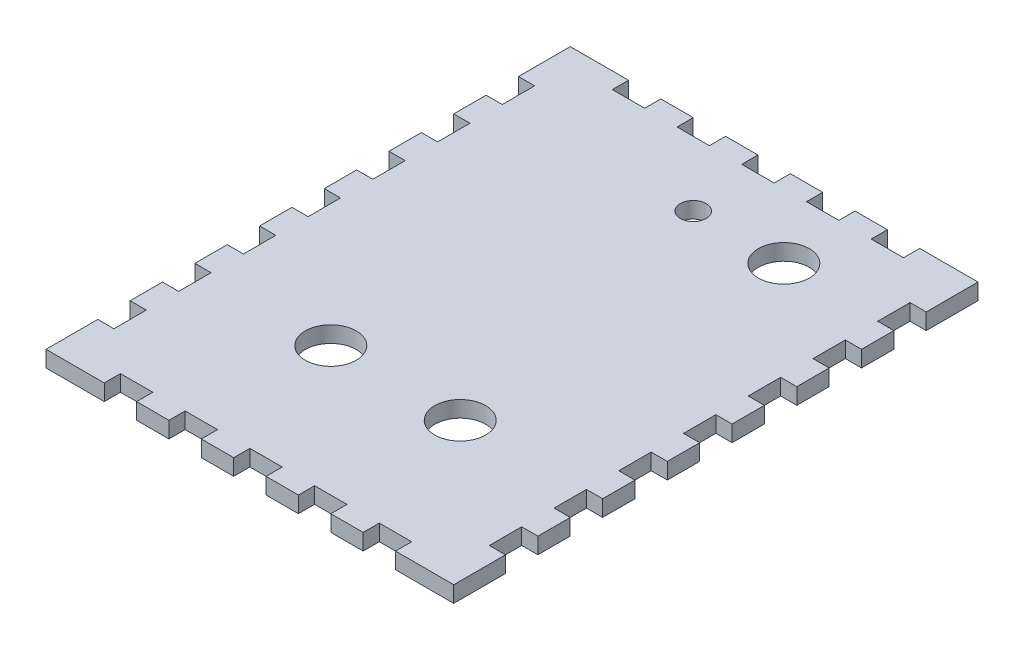
from build123d import *

# Parameters (mm, degrees)
SKETCH1_W           = 80.01
SKETCH1_H           = 102.87
BOSS_EXTRUDE1_DEPTH = 3.175
SKETCH2_W           = 3.175
SKETCH2_H           = 6.35
CUT_EXTRUDE1_DEPTH  = 4.175
SKETCH3_W           = 6.35
SKETCH3_H           = 3.175
CUT_EXTRUDE2_DEPTH  = 4.175
SKETCH4_R           = 2.54
SKETCH4_R_2         = 5
CUT_EXTRUDE3_DEPTH  = 4.175


with BuildPart() as part:
    # Sketch1 → Boss-Extrude1 (new body)
    with BuildSketch(Plane(origin=(0, 0, 0), x_dir=(1, 0, 0), z_dir=(0, 1, 0))):
        Rectangle(SKETCH1_W, SKETCH1_H)
    extrude(amount=BOSS_EXTRUDE1_DEPTH)

    # Sketch2 → Cut-Extrude1 (cut, through all)
    with BuildSketch(Plane(origin=(0, 3.175, 0), x_dir=(1, 0, 0), z_dir=(0, 1, 0))):
        with Locations((-38.4175, -38.1)):
            Rectangle(SKETCH2_W, SKETCH2_H)
        with Locations((-38.4175, -25.4)):
            Rectangle(SKETCH2_W, SKETCH2_H)
        with Locations((-38.4175, -12.7)):
            Rectangle(SKETCH2_W, SKETCH2_H)
        with Locations((-38.4175, 0)):
            Rectangle(SKETCH2_W, SKETCH2_H)
        with Locations((-38.4175, 12.7)):
            Rectangle(SKETCH2_W, SKETCH2_H)
        with Locations((-38.4175, 25.4)):
            Rectangle(SKETCH2_W, SKETCH2_H)
        with Locations((38.4175, 25.4)):
            Rectangle(SKETCH2_W, SKETCH2_H)
        with Locations((38.4175, 12.7)):
            Rectangle(SKETCH2_W, SKETCH2_H)
        with Locations((38.4175, 0)):
            Rectangle(SKETCH2_W, SKETCH2_H)
        with Locations((38.4175, -12.7)):
            Rectangle(SKETCH2_W, SKETCH2_H)
        with Locations((38.4175, -25.4)):
            Rectangle(SKETCH2_W, SKETCH2_H)
        with Locations((38.4175, -38.1)):
            Rectangle(SKETCH2_W, SKETCH2_H)
        with Locations((-38.4175, 38.1)):
            Rectangle(SKETCH2_W, SKETCH2_H)
        with Locations((38.4175, 38.1)):
            Rectangle(SKETCH2_W, SKETCH2_H)
    extrude(amount=-CUT_EXTRUDE1_DEPTH, mode=Mode.SUBTRACT)

    # Sketch3 → Cut-Extrude2 (cut, through all)
    with BuildSketch(Plane(origin=(0, 3.175, 0), x_dir=(1, 0, 0), z_dir=(0, 1, 0))):
        with Locations((25.4, 49.8475)):
            Rectangle(SKETCH3_W, SKETCH3_H)
        with Locations((12.7, 49.8475)):
            Rectangle(SKETCH3_W, SKETCH3_H)
        with Locations((0, 49.8475)):
            Rectangle(SKETCH3_W, SKETCH3_H)
        with Locations((-12.7, 49.8475)):
            Rectangle(SKETCH3_W, SKETCH3_H)
        with Locations((-12.7, -49.8475)):
            Rectangle(SKETCH3_W, SKETCH3_H)
        with Locations((0, -49.8475)):
            Rectangle(SKETCH3_W, SKETCH3_H)
        with Locations((12.7, -49.8475)):
            Rectangle(SKETCH3_W, SKETCH3_H)
        with Locations((25.4, -49.8475)):
            Rectangle(SKETCH3_W, SKETCH3_H)
        with Locations((-25.4, -49.8475)):
            Rectangle(SKETCH3_W, SKETCH3_H)
        with Locations((-25.4, 49.8475)):
            Rectangle(SKETCH3_W, SKETCH3_H)
    extrude(amount=-CUT_EXTRUDE2_DEPTH, mode=Mode.SUBTRACT)

    # Sketch4 → Cut-Extrude3 (cut, through all)
    with BuildSketch(Plane(origin=(0, 3.175, 0), x_dir=(1, 0, 0), z_dir=(0, 1, 0))):
        with Locations((0, 35.56)):
            Circle(SKETCH4_R)
        with Locations((17.78, 35.56)):
            Circle(SKETCH4_R_2)
        with Locations((12.7, -22.86)):
            Circle(SKETCH4_R_2)
        with Locations((-12.7, -22.86)):
            Circle(SKETCH4_R_2)
    extrude(amount=-CUT_EXTRUDE3_DEPTH, mode=Mode.SUBTRACT)


solid = part.part
